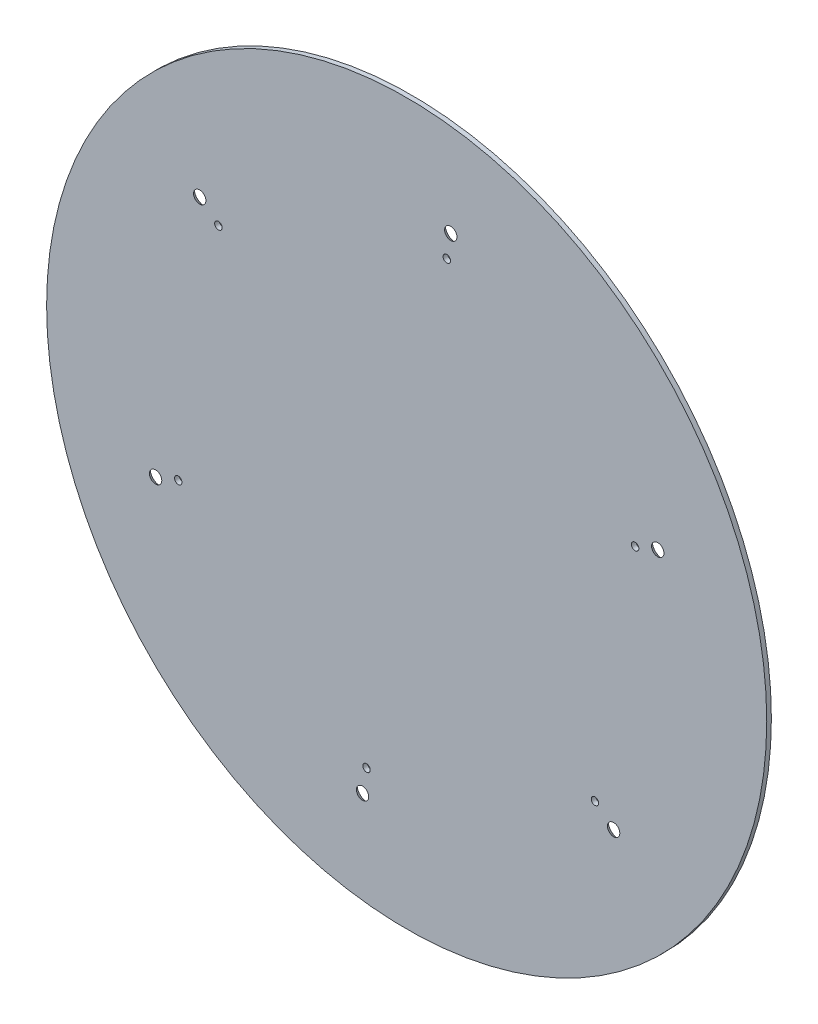
from build123d import *

# Parameters (mm, degrees)
SKETCH1_R                                         = 155
BOSS_EXTRUDE1_DEPTH                               = 2
SKETCH3_R                                         = 1.6
CUT_EXTRUDE2_DEPTH                                = 10
CSK_FOR_8_FLAT_HEAD_MACHINE_SCREW_100_D           = 4.4958
CSK_FOR_8_FLAT_HEAD_MACHINE_SCREW_100_DEPTH       = 10.71
CSK_FOR_8_FLAT_HEAD_MACHINE_SCREW_100_CSINK_D     = 8.780526
CSK_FOR_8_FLAT_HEAD_MACHINE_SCREW_100_CSINK_ANGLE = 82
CSK_FOR_8_FLAT_HEAD_MACHINE_SCREW_100_TIP         = 1.350674586


with BuildPart() as part:
    # Sketch1 → Boss-Extrude1 (new body)
    with BuildSketch(Plane.XY):
        Circle(SKETCH1_R)
    extrude(amount=BOSS_EXTRUDE1_DEPTH)

    # Sketch3 → Cut-Extrude2 (cut)
    with BuildSketch(Plane.XY.offset(2)):
        with Locations((17.280155357, 103.568316733)):
            Circle(SKETCH3_R)
        with Locations((-81.052715639, 66.749211887)):
            Circle(SKETCH3_R)
        with Locations((-98.332870996, -36.819104846)):
            Circle(SKETCH3_R)
        with Locations((-17.280155357, -103.568316733)):
            Circle(SKETCH3_R)
        with Locations((81.052715639, -66.749211887)):
            Circle(SKETCH3_R)
        with Locations((98.332870996, 36.819104846)):
            Circle(SKETCH3_R)
    extrude(amount=-CUT_EXTRUDE2_DEPTH, mode=Mode.SUBTRACT)

    # CSK for #8 Flat Head Machine Screw (100)1
    with Locations(Plane(origin=(0, 0, 0), x_dir=(-1, 0, 0), z_dir=(0, 0, -1))):
        with Locations((-18.981218556, 113.83840056), (89.088513447, 73.366919465), (108.077556089, -40.480982816), (-108.077556089, 40.480982816), (-89.088513447, -73.366919465), (18.981218556, -113.83840056)):
            CounterSinkHole(CSK_FOR_8_FLAT_HEAD_MACHINE_SCREW_100_D / 2, CSK_FOR_8_FLAT_HEAD_MACHINE_SCREW_100_CSINK_D / 2, depth=CSK_FOR_8_FLAT_HEAD_MACHINE_SCREW_100_DEPTH, counter_sink_angle=CSK_FOR_8_FLAT_HEAD_MACHINE_SCREW_100_CSINK_ANGLE)
            with Locations((0, 0, -(CSK_FOR_8_FLAT_HEAD_MACHINE_SCREW_100_DEPTH + CSK_FOR_8_FLAT_HEAD_MACHINE_SCREW_100_TIP / 2))):  # 118° drill point
                Cone(0, CSK_FOR_8_FLAT_HEAD_MACHINE_SCREW_100_D / 2, CSK_FOR_8_FLAT_HEAD_MACHINE_SCREW_100_TIP, mode=Mode.SUBTRACT)


solid = part.part
